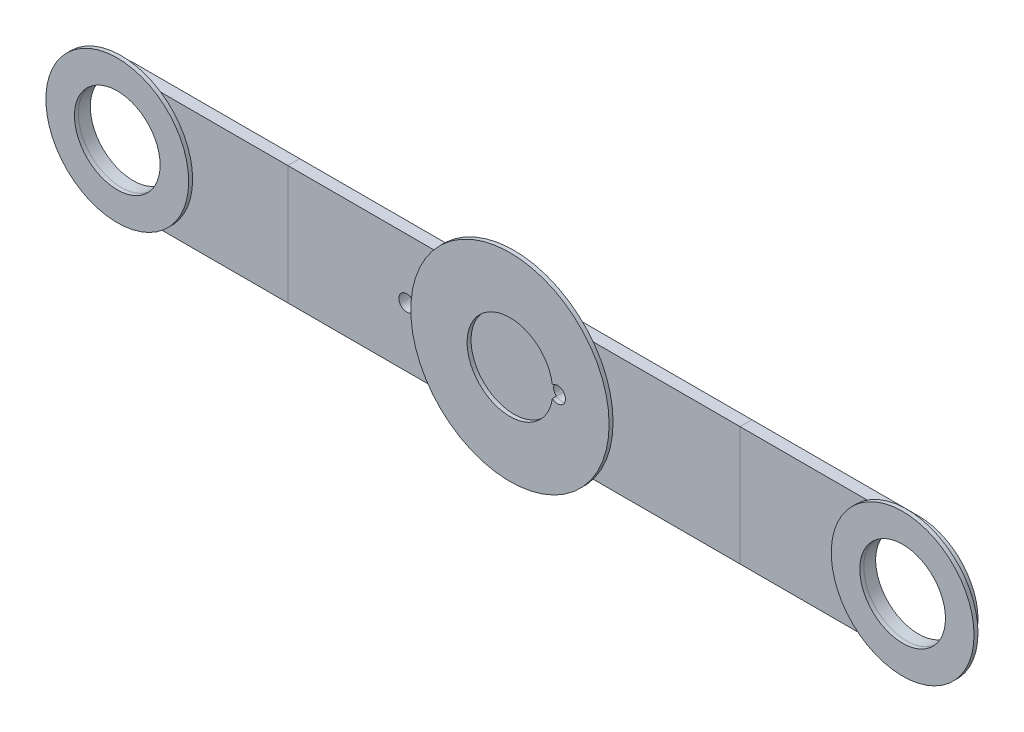
from build123d import *

# Parameters (mm, degrees)
SKETCH1_R               = 5.4
BOSS_EXTRUDE1_DEPTH     = 1.5
BOSS_EXTRUDE1_2_DEPTH   = 1.5
SKETCH2_W               = 57
SKETCH2_H               = 15
SKETCH2_R               = 5.4
BOSS_EXTRUDE2_DEPTH     = 1.5
SKETCH3_R               = 12.5
SKETCH3_R_2             = 5.4
BOSS_EXTRUDE3_DEPTH     = 0.5
SKETCH3_R_3             = 9
BOSS_EXTRUDE3_2_DEPTH   = 0.5
BOSS_EXTRUDE3_3_DEPTH   = 0.5
SKETCH4_R               = 5.4
BOSS_EXTRUDE4_DEPTH     = 1.5
SKETCH5_R               = 1
CUT_EXTRUDE1_DEPTH      = 1.5
CUT_EXTRUDE1_DEPTH_BACK = 2.5


with BuildPart() as part:
    # Sketch1 → Boss-Extrude1 (new body)
    with BuildSketch(Plane.XY):
        with BuildLine():
            ThreePointArc((-49.5, -7.5), (-57, 0), (-49.5, 7.5))
            Line((-49.5, 7.5), (-28.5, 7.5))
            Line((-28.5, 7.5), (-28.5, -7.5))
            Line((-28.5, -7.5), (-49.5, -7.5))
        make_face()
        with Locations((-49.5, 0)):
            Circle(SKETCH1_R, mode=Mode.SUBTRACT)
    extrude(amount=BOSS_EXTRUDE1_DEPTH)


with BuildPart() as body_2:
    # Sketch1 → Boss-Extrude1 2 (new body)
    with BuildSketch(Plane.XY):
        with BuildLine():
            Line((49.5, -7.5), (28.5, -7.5))
            Line((28.5, -7.5), (28.5, 7.5))
            Line((28.5, 7.5), (49.5, 7.5))
            ThreePointArc((49.5, 7.5), (57, 0), (49.5, -7.5))
        make_face()
        with Locations((49.5, 0)):
            Circle(SKETCH1_R, mode=Mode.SUBTRACT)
    extrude(amount=BOSS_EXTRUDE1_2_DEPTH)


with BuildPart() as body_3:
    # Sketch2 → Boss-Extrude2 (new body)
    with BuildSketch(Plane.XY.offset(1.5)):
        Rectangle(SKETCH2_W, SKETCH2_H)
        Circle(SKETCH2_R, mode=Mode.SUBTRACT)
    extrude(amount=-BOSS_EXTRUDE2_DEPTH)


with BuildPart() as body_4:
    # Sketch3 → Boss-Extrude3 (new body)
    with BuildSketch(Plane.XY.offset(1.5)):
        Circle(SKETCH3_R)
        Circle(SKETCH3_R_2, mode=Mode.SUBTRACT)
    extrude(amount=BOSS_EXTRUDE3_DEPTH)


with BuildPart() as body_5:
    # Sketch3 → Boss-Extrude3 2 (new body)
    with BuildSketch(Plane.XY.offset(1.5)):
        with Locations((49.5, 0)):
            Circle(SKETCH3_R_3)
        with Locations((49.5, 0)):
            Circle(SKETCH3_R_2, mode=Mode.SUBTRACT)
    extrude(amount=BOSS_EXTRUDE3_2_DEPTH)


with BuildPart() as body_6:
    # Sketch3 → Boss-Extrude3 3 (new body)
    with BuildSketch(Plane.XY.offset(1.5)):
        with Locations((-49.5, 0)):
            Circle(SKETCH3_R_3)
        with Locations((-49.5, 0)):
            Circle(SKETCH3_R_2, mode=Mode.SUBTRACT)
    extrude(amount=BOSS_EXTRUDE3_3_DEPTH)


with BuildPart() as body_7:
    # Sketch4 → Boss-Extrude4 (new body)
    with BuildSketch(Plane.XY.offset(1.5)):
        Circle(SKETCH4_R)
    extrude(amount=-BOSS_EXTRUDE4_DEPTH)


with BuildPart() as cut_extrude1_tool:
    # Sketch5 → Cut-Extrude1 (new body, two sides)
    with BuildSketch(Plane.XY.offset(1.5)) as cut_extrude1_sk:
        with Locations((-13.5, 0)):
            Circle(SKETCH5_R)
        with Locations((6, 0)):
            Circle(SKETCH5_R)
    extrude(amount=CUT_EXTRUDE1_DEPTH)
    extrude(cut_extrude1_sk.sketch, amount=-CUT_EXTRUDE1_DEPTH_BACK)


with BuildPart() as body_3_1:
    add(body_3.part)

    # Cut-Extrude1: cut by cut_extrude1_tool
    add(cut_extrude1_tool.part, mode=Mode.SUBTRACT)


with BuildPart() as body_4_1:
    add(body_4.part)

    # Cut-Extrude1: cut by cut_extrude1_tool
    add(cut_extrude1_tool.part, mode=Mode.SUBTRACT)


with BuildPart() as body_7_1:
    add(body_7.part)

    # Cut-Extrude1: cut by cut_extrude1_tool
    add(cut_extrude1_tool.part, mode=Mode.SUBTRACT)


solid = Compound([part.part, body_2.part, body_5.part, body_6.part, body_3_1.part, body_4_1.part, body_7_1.part])
